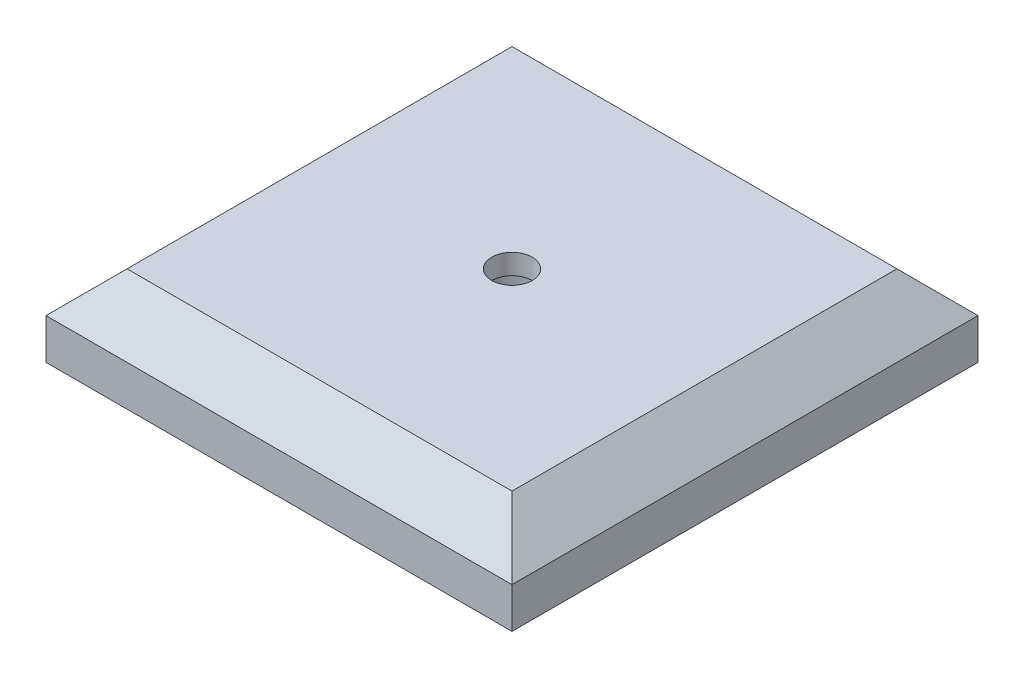
from build123d import *

# Parameters (mm, degrees)
SKETCH1_W           = 73.025
SKETCH1_H           = 73.025
BOSS_EXTRUDE1_DEPTH = 12.7
CHAMFER1_SIZE       = 6.35
SKETCH4_R           = 3.175
CUT_EXTRUDE1_DEPTH  = 3.175
CUT_EXTRUDE2_REACH  = 11.525
SKETCH5_R           = 6.35


with BuildPart() as part:
    # Sketch1 → Boss-Extrude1 (new body)
    with BuildSketch(Plane(origin=(0, 0, 0), x_dir=(1, 0, 0), z_dir=(0, 1, 0))):
        Rectangle(SKETCH1_W, SKETCH1_H)
    extrude(amount=BOSS_EXTRUDE1_DEPTH)

    # Chamfer1
    chamfer1_edges = [part.edges().sort_by_distance(p)[0] for p in [
        (-36.5125, 12.7, 0),
        (0, 12.7, 36.5125),
        (36.5125, 12.7, 0),
        (0, 12.7, -36.5125),
    ]]
    chamfer(chamfer1_edges, length=CHAMFER1_SIZE)

    # Sketch4 → Cut-Extrude1 (cut)
    with BuildSketch(Plane(origin=(0, 12.7, 0), x_dir=(1, 0, 0), z_dir=(0, 1, 0))):
        Circle(SKETCH4_R)
    extrude(amount=-CUT_EXTRUDE1_DEPTH, mode=Mode.SUBTRACT)

    # Sketch5 → Cut-Extrude2 (cut, up to next)
    with BuildSketch(Plane(origin=(0, 9.525, 0), x_dir=(1, 0, 0), z_dir=(0, 1, 0)), mode=Mode.PRIVATE) as cut_extrude2_sk1:
        Circle(SKETCH5_R)
    cut_extrude2_tool1 = extrude(cut_extrude2_sk1.sketch, amount=-CUT_EXTRUDE2_REACH, mode=Mode.PRIVATE) & part.part
    add(cut_extrude2_tool1.solids().sort_by_distance((0, 9.525, 0))[0], mode=Mode.SUBTRACT)


solid = part.part
